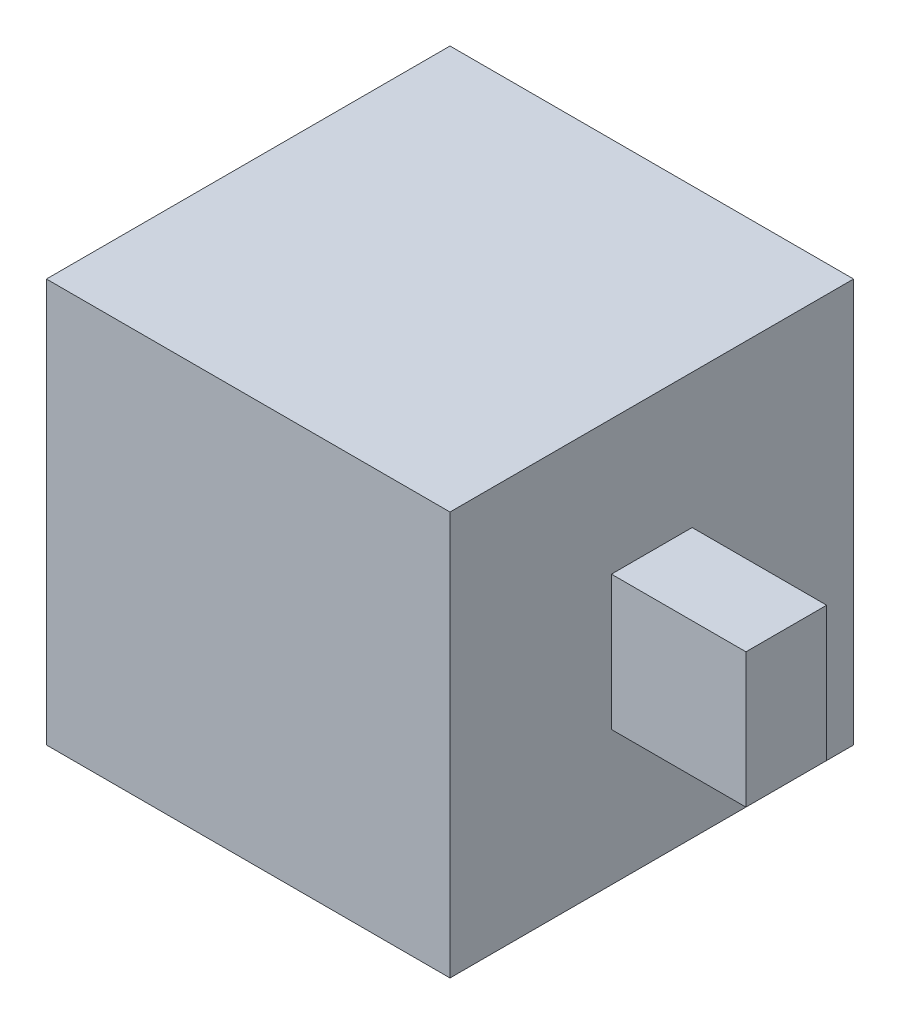
from build123d import *

# Parameters (mm, degrees)
SKETCH_1_W      = 30
SKETCH_1_H      = 30
EXTRUDE_1_DEPTH = 30
SKETCH_2_W      = 6
SKETCH_2_H      = 10
EXTRUDE_2_DEPTH = 10


with BuildPart() as part:
    # 草图1 → 凸台-拉伸1 (new body)
    with BuildSketch(Plane(origin=(0, 0, 0), x_dir=(0, 0, -1), z_dir=(1, 0, 0))):
        with Locations((15, 15)):
            Rectangle(SKETCH_1_W, SKETCH_1_H)
    extrude(amount=EXTRUDE_1_DEPTH)

    # 草图2 → 凸台-拉伸2 (add)
    with BuildSketch(Plane(origin=(30, 0, 0), x_dir=(0, 0, -1), z_dir=(1, 0, 0))):
        with Locations((15, 15)):
            Rectangle(SKETCH_2_W, SKETCH_2_H)
    extrude(amount=EXTRUDE_2_DEPTH)


solid = part.part
